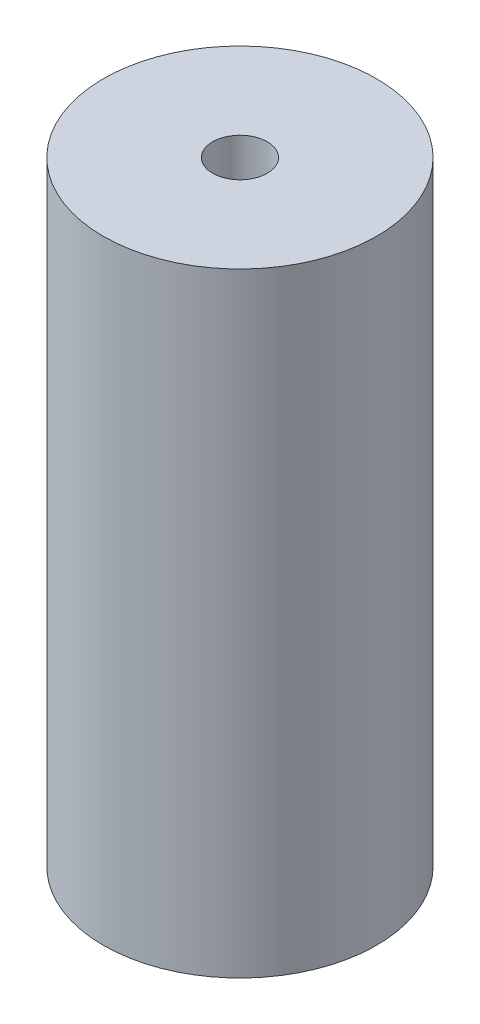
from build123d import *

# Parameters (mm, degrees)
SKETCH1_R           = 7.9375
SKETCH1_R_2         = 1.5875
BOSS_EXTRUDE1_DEPTH = 17.8435


with BuildPart() as part:
    # Sketch1 → Boss-Extrude1 (new, symmetric)
    with BuildSketch(Plane(origin=(0, 0, 0), x_dir=(1, 0, 0), z_dir=(0, 1, 0))):
        Circle(SKETCH1_R)
        Circle(SKETCH1_R_2, mode=Mode.SUBTRACT)
    extrude(amount=BOSS_EXTRUDE1_DEPTH, both=True)


solid = part.part
